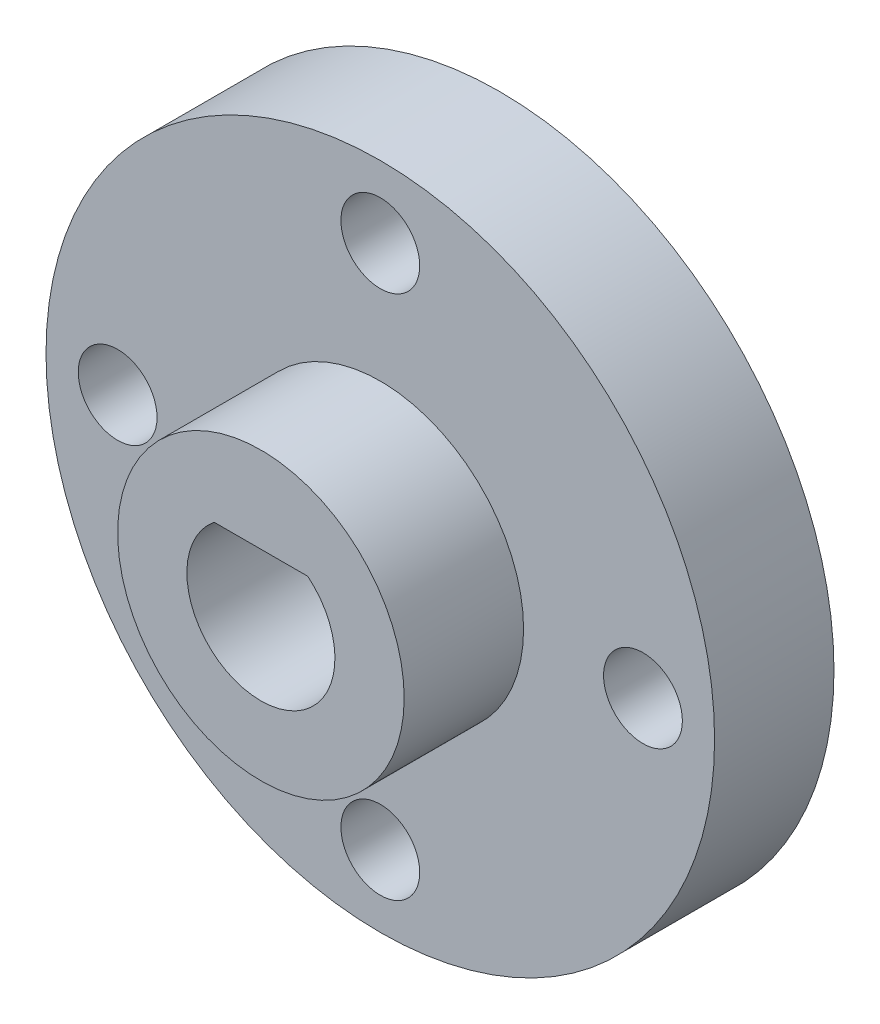
from build123d import *

# Parameters (mm, degrees)
SKETCH1_R           = 14
SKETCH1_R_2         = 1.65
BOSS_EXTRUDE1_DEPTH = 5
SKETCH2_R           = 6
BOSS_EXTRUDE2_DEPTH = 5
CUT_EXTRUDE1_DEPTH  = 11


with BuildPart() as part:
    # Sketch1 → Boss-Extrude1 (new body)
    with BuildSketch(Plane.XY):
        Circle(SKETCH1_R)
        with Locations((0, 11)):
            Circle(SKETCH1_R_2, mode=Mode.SUBTRACT)
        with Locations((11, 0)):
            Circle(SKETCH1_R_2, mode=Mode.SUBTRACT)
        with Locations((0, -11)):
            Circle(SKETCH1_R_2, mode=Mode.SUBTRACT)
        with Locations((-11, 0)):
            Circle(SKETCH1_R_2, mode=Mode.SUBTRACT)
    extrude(amount=BOSS_EXTRUDE1_DEPTH)

    # Sketch2 → Boss-Extrude2 (add)
    with BuildSketch(Plane.XY.offset(5)):
        Circle(SKETCH2_R)
    extrude(amount=BOSS_EXTRUDE2_DEPTH)

    # Sketch3 → Cut-Extrude1 (cut, through all)
    with BuildSketch(Plane.XY.offset(10)):
        with BuildLine():
            Line((-1.962141687, 2.4), (1.962141687, 2.4))
            ThreePointArc((1.962141687, 2.4), (0, -3.1), (-1.962141687, 2.4))
        make_face()
    extrude(amount=-CUT_EXTRUDE1_DEPTH, mode=Mode.SUBTRACT)


solid = part.part
